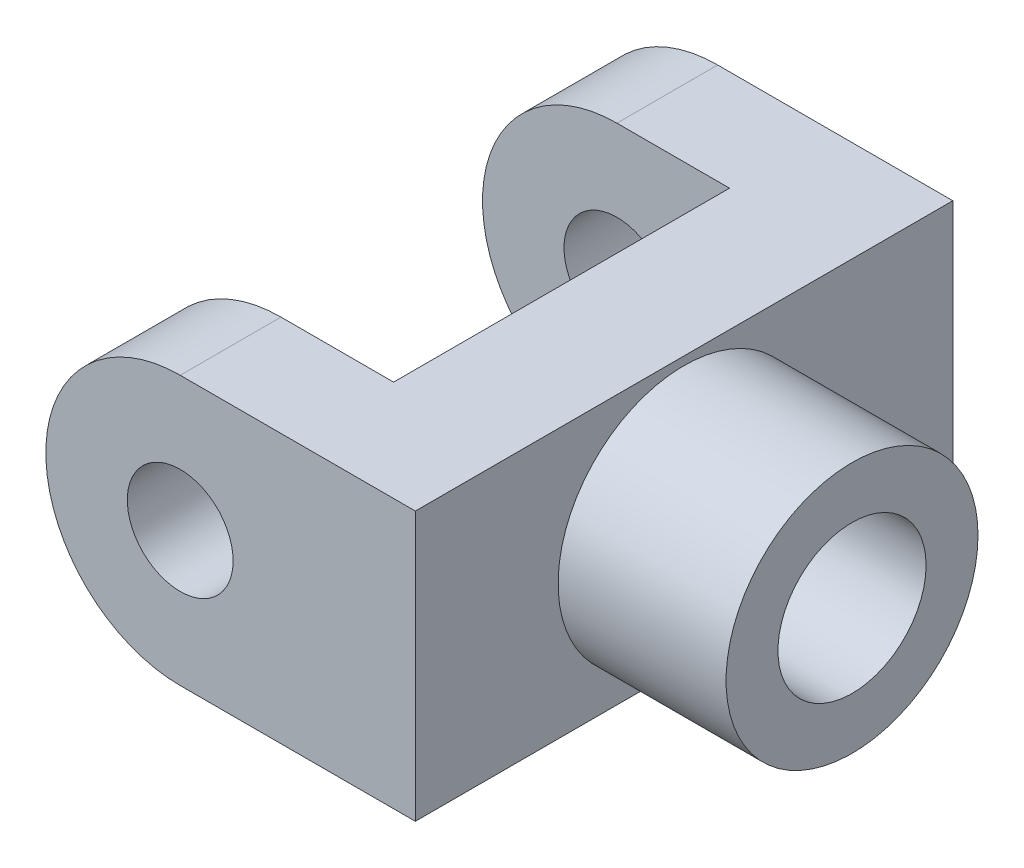
from build123d import *

# Parameters (mm, degrees)
SKETCH2_R           = 2
BOSS_EXTRUDE1_DEPTH = 20.32
SKETCH3_R           = 2
CUT_EXTRUDE1_DEPTH  = 6.35
SKETCH4_R           = 4.7625
BOSS_EXTRUDE2_DEPTH = 6.35
SKETCH5_R           = 2.8
CUT_EXTRUDE2_DEPTH  = 4.7
CHAMFER2_SIZE       = 2.54
CHAMFER2_SIZE2      = 0.447870531


with BuildPart() as part:
    # Sketch2 → Boss-Extrude1 (new body)
    with BuildSketch(Plane.XY):
        with BuildLine():
            ThreePointArc((0, 5.08), (-5.08, 0), (0, -5.08))
            Line((0, -5.08), (8.89, -5.08))
            Line((8.89, -5.08), (8.89, 5.08))
            Line((8.89, 5.08), (0, 5.08))
        make_face()
        Circle(SKETCH2_R, mode=Mode.SUBTRACT)
    extrude(amount=BOSS_EXTRUDE1_DEPTH)

    # Sketch3 → Cut-Extrude1 (cut, symmetric)
    with BuildSketch(Plane.XY.offset(10.16)):
        with BuildLine():
            ThreePointArc((0, 5.08), (-5.08, 0), (0, -5.08))
            ThreePointArc((0, -5.08), (2.090104165, -4.630104165), (3.81, -3.360104165))
            Line((3.81, -3.360104165), (3.81, 3.360104165))
            ThreePointArc((3.81, 3.360104165), (2.090104165, 4.630104165), (0, 5.08))
        make_face()
        Circle(SKETCH3_R, mode=Mode.SUBTRACT)
        with BuildLine():
            Line((3.81, 5.08), (0, 5.08))
            ThreePointArc((0, 5.08), (2.090104165, 4.630104165), (3.81, 3.360104165))
            Line((3.81, 3.360104165), (3.81, 5.08))
        make_face()
        with BuildLine():
            Line((0, -5.08), (3.81, -5.08))
            Line((3.81, -5.08), (3.81, -3.360104165))
            ThreePointArc((3.81, -3.360104165), (2.090104165, -4.630104165), (0, -5.08))
        make_face()
    extrude(amount=CUT_EXTRUDE1_DEPTH, both=True, mode=Mode.SUBTRACT)

    # Sketch4 → Boss-Extrude2 (add)
    with BuildSketch(Plane(origin=(8.89, 0, 0), x_dir=(0, 0, -1), z_dir=(1, 0, 0))):
        with Locations((-10.16, 0)):
            Circle(SKETCH4_R)
    extrude(amount=BOSS_EXTRUDE2_DEPTH)

    # Sketch5 → Cut-Extrude2 (cut)
    with BuildSketch(Plane(origin=(15.24, 0, 0), x_dir=(0, 0, -1), z_dir=(1, 0, 0))):
        with Locations((-10.16, 0)):
            Circle(SKETCH5_R)
    extrude(amount=-CUT_EXTRUDE2_DEPTH, mode=Mode.SUBTRACT)

    # Chamfer2
    chamfer2_edges = [part.edges().sort_by_distance(p)[0] for p in [
        (3.81, 5.08, 10.16),
        (3.81, -5.08, 10.16),
    ]]
    chamfer2_side = [part.faces().sort_by_distance(p)[0] for p in [
        (3.81, 0, 10.16),
    ]]
    chamfer(chamfer2_edges, length=CHAMFER2_SIZE, length2=CHAMFER2_SIZE2, reference=chamfer2_side[0])


solid = part.part
